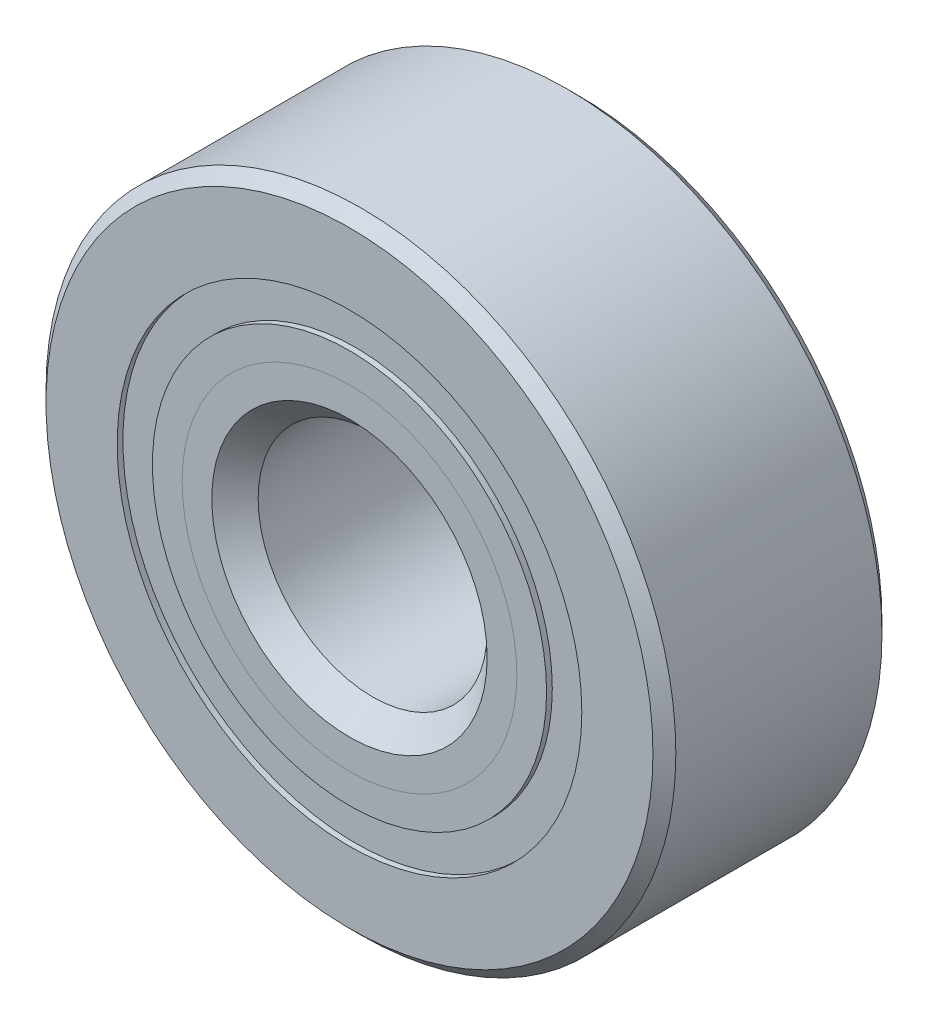
from build123d import *

# Parameters (mm, degrees)
CIRPATTERN1_COUNT = 8
SKETCH5_W         = 1.522988723
SKETCH5_H         = 0.976923076


with BuildPart() as part:
    # Sketch1 → Revolve1 (revolve)
    with BuildSketch(Plane(origin=(0, 0, 0), x_dir=(0, 0, -1), z_dir=(1, 0, 0))):
        with BuildLine():
            Line((2.8575, 8.73125), (-2.8575, 8.73125))
            Line((-2.8575, 8.73125), (-3.175, 8.41375))
            Line((-3.175, 8.41375), (-3.175, 6.441586538))
            Line((-3.175, 6.441586538), (-1.411111111, 6.441586538))
            ThreePointArc((-1.411111111, 6.441586538), (0, 7.446386277), (1.411111111, 6.441586538))
            Line((1.411111111, 6.441586538), (3.175, 6.441586538))
            Line((3.175, 6.441586538), (3.175, 8.41375))
            Line((3.175, 8.41375), (2.8575, 8.73125))
        make_face()
    revolve(axis=Axis((0, 0, 3.175), (0, 0, -1)))


with BuildPart() as body_2:
    # Sketch2 → Revolve2 (revolve)
    with BuildSketch(Plane(origin=(0, 0, 0), x_dir=(0, 0, -1), z_dir=(1, 0, 0))):
        with BuildLine():
            Line((-3.175, 5.464663462), (-1.411111111, 5.464663462))
            ThreePointArc((-1.411111111, 5.464663462), (-0.866149104, 4.73673075), (0, 4.459863723))
            Line((0, 4.459863723), (0, 3.817431861))
            Line((0, 3.817431861), (-2.3513842, 3.817431861))
            Line((-2.3513842, 3.817431861), (-3.175, 4.641047661))
            Line((-3.175, 4.641047661), (-3.175, 5.464663462))
        make_face()
    revolve(axis=Axis((0, 0, 3.175), (0, 0, -1)))


with BuildPart() as body_3:
    # Sketch3 → Revolve3 (revolve)
    with BuildSketch(Plane(origin=(0, 0, 0), x_dir=(0, 0, -1), z_dir=(1, 0, 0))):
        with BuildLine():
            Line((-3.175, 4.641047661), (-2.3513842, 3.817431861))
            Line((-2.3513842, 3.817431861), (0, 3.817431861))
            Line((0, 3.817431861), (0, 4.459863723))
            ThreePointArc((0, 4.459863723), (0.866149104, 4.73673075), (1.411111111, 5.464663462))
            Line((1.411111111, 5.464663462), (3.175, 5.464663462))
            Line((3.175, 5.464663462), (3.175, 3.4925))
            Line((3.175, 3.4925), (2.8575, 3.175))
            Line((2.8575, 3.175), (-2.532568139, 3.175))
            Line((-2.532568139, 3.175), (-3.175, 3.817431861))
            Line((-3.175, 3.817431861), (-3.175, 4.641047661))
        make_face()
    revolve(axis=Axis((0, 0, 3.175), (0, 0, -1)))


with BuildPart() as body_4:
    # Sketch4 → Revolve4 (revolve)
    with BuildSketch(Plane(origin=(0, 0, 0), x_dir=(0, 0, -1), z_dir=(1, 0, 0))):
        with BuildLine():
            Line((-1.493261277, 5.953125), (1.493261277, 5.953125))
            ThreePointArc((1.493261277, 5.953125), (0, 7.446386277), (-1.493261277, 5.953125))
        make_face()
    revolve(axis=Axis((0, 5.953125, 1.493261277), (0, 0, -1)))


with BuildPart() as cirpattern1_1:
    # CirPattern1: pattern copy
    add(body_4.part.rotate(Axis((0, 0, -3.175), (0, 0, 1)), 1 * 360 / CIRPATTERN1_COUNT))


with BuildPart() as cirpattern1_2:
    # CirPattern1: pattern copy
    add(body_4.part.rotate(Axis((0, 0, -3.175), (0, 0, 1)), 2 * 360 / CIRPATTERN1_COUNT))


with BuildPart() as cirpattern1_3:
    # CirPattern1: pattern copy
    add(body_4.part.rotate(Axis((0, 0, -3.175), (0, 0, 1)), 3 * 360 / CIRPATTERN1_COUNT))


with BuildPart() as cirpattern1_4:
    # CirPattern1: pattern copy
    add(body_4.part.rotate(Axis((0, 0, -3.175), (0, 0, 1)), 4 * 360 / CIRPATTERN1_COUNT))


with BuildPart() as cirpattern1_5:
    # CirPattern1: pattern copy
    add(body_4.part.rotate(Axis((0, 0, -3.175), (0, 0, 1)), 5 * 360 / CIRPATTERN1_COUNT))


with BuildPart() as cirpattern1_6:
    # CirPattern1: pattern copy
    add(body_4.part.rotate(Axis((0, 0, -3.175), (0, 0, 1)), 6 * 360 / CIRPATTERN1_COUNT))


with BuildPart() as cirpattern1_7:
    # CirPattern1: pattern copy
    add(body_4.part.rotate(Axis((0, 0, -3.175), (0, 0, 1)), 7 * 360 / CIRPATTERN1_COUNT))


with BuildPart() as body_12:
    # Sketch5 → Revolve5 (revolve)
    with BuildSketch(Plane(origin=(0, 0, 0), x_dir=(0, 0, -1), z_dir=(1, 0, 0))):
        with Locations((-2.254755639, 5.953125)):
            Rectangle(SKETCH5_W, SKETCH5_H)
        with Locations((2.254755639, 5.953125)):
            Rectangle(SKETCH5_W, SKETCH5_H)
    revolve(axis=Axis((0, 0, 3.175), (0, 0, -1)))


solid = Compound([part.part, body_2.part, body_3.part, body_4.part, cirpattern1_1.part, cirpattern1_2.part, cirpattern1_3.part, cirpattern1_4.part, cirpattern1_5.part, cirpattern1_6.part, cirpattern1_7.part, body_12.part])
